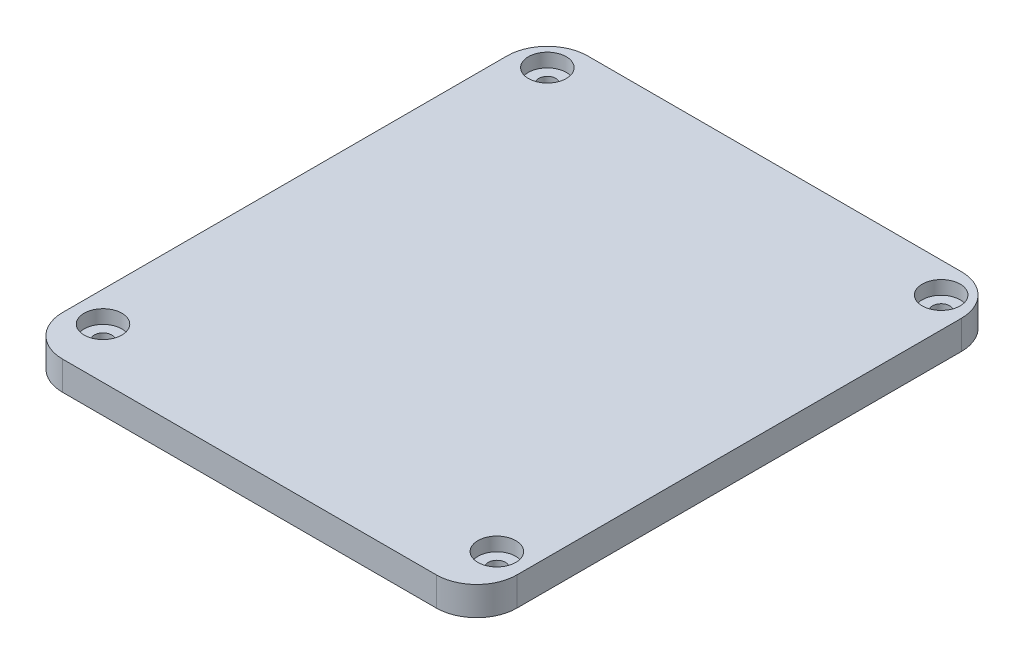
from build123d import *

# Parameters (mm, degrees)
SKETCH1_W           = 90
SKETCH1_H           = 100
BOSS_EXTRUDE1_DEPTH = 3
SKETCH2_R           = 1.7
CUT_EXTRUDE1_DEPTH  = 4
SKETCH4_W           = 80.2
SKETCH4_H           = 93.2
SKETCH4_W_2         = 74.2
SKETCH4_H_2         = 87.2
BOSS_EXTRUDE2_DEPTH = 2
CUT_EXTRUDE5_START  = -3
SKETCH6_R           = 6
CUT_EXTRUDE5_DEPTH  = 3
SKETCH7_W           = 90
SKETCH7_H           = 3
BOSS_EXTRUDE3_DEPTH = 4
SKETCH8_R           = 3.75
BOSS_EXTRUDE4_DEPTH = 2.7
FILLET1_R           = 8


with BuildPart() as part:
    # Sketch1 → Boss-Extrude1 (new body)
    with BuildSketch(Plane(origin=(0, 0, 0), x_dir=(1, 0, 0), z_dir=(0, 1, 0))):
        Rectangle(SKETCH1_W, SKETCH1_H)
    extrude(amount=BOSS_EXTRUDE1_DEPTH)

    # Sketch2 → Cut-Extrude1 (cut, through all)
    with BuildSketch(Plane(origin=(0, 3, 0), x_dir=(1, 0, 0), z_dir=(0, 1, 0))):
        with Locations((-39, 44)):
            Circle(SKETCH2_R)
        with Locations((39, 44)):
            Circle(SKETCH2_R)
        with Locations((39, -44)):
            Circle(SKETCH2_R)
        with Locations((-39, -44)):
            Circle(SKETCH2_R)
    extrude(amount=-CUT_EXTRUDE1_DEPTH, mode=Mode.SUBTRACT)

    # Sketch4 → Boss-Extrude2 (add)
    with BuildSketch(Plane.XZ):
        with Locations((1.5, 0)):
            Rectangle(SKETCH4_W, SKETCH4_H)
        with Locations((1.5, 0)):
            Rectangle(SKETCH4_W_2, SKETCH4_H_2, mode=Mode.SUBTRACT)
    extrude(amount=BOSS_EXTRUDE2_DEPTH)

    # Sketch6 → Cut-Extrude5 (cut, through all)
    with BuildSketch(Plane(origin=(0, 3, 0), x_dir=(1, 0, 0), z_dir=(0, 1, 0)).offset(CUT_EXTRUDE5_START)):
        with Locations((-39, 44)):
            Circle(SKETCH6_R)
        with Locations((-39, -44)):
            Circle(SKETCH6_R)
        with Locations((39, -44)):
            Circle(SKETCH6_R)
        with Locations((39, 44)):
            Circle(SKETCH6_R)
    extrude(amount=-CUT_EXTRUDE5_DEPTH, mode=Mode.SUBTRACT)

    # Sketch7 → Boss-Extrude3 (add)
    with BuildSketch(Plane.XY.offset(50)):
        with Locations((0, 1.5)):
            Rectangle(SKETCH7_W, SKETCH7_H)
    extrude(amount=BOSS_EXTRUDE3_DEPTH)

    # Sketch8 → Boss-Extrude4 (add)
    with BuildSketch(Plane(origin=(0, 3, 0), x_dir=(1, 0, 0), z_dir=(0, 1, 0))):
        Polygon((-45, -50), (-45, -54), (45, -54), (45, -50), (45, 50), (-45, 50), align=None)
        with Locations((-39, 44)):
            Circle(SKETCH8_R, mode=Mode.SUBTRACT)
        with Locations((39, 44)):
            Circle(SKETCH8_R, mode=Mode.SUBTRACT)
        with Locations((-39, -44)):
            Circle(SKETCH8_R, mode=Mode.SUBTRACT)
        with Locations((39, -44)):
            Circle(SKETCH8_R, mode=Mode.SUBTRACT)
    extrude(amount=BOSS_EXTRUDE4_DEPTH)

    # Fillet1
    fillet1_edges = [part.edges().sort_by_distance(p)[0] for p in [
        (-45, 2.85, 54),
        (45, 2.85, 54),
        (-45, 2.85, -50),
        (45, 2.85, -50),
    ]]
    fillet(fillet1_edges, radius=FILLET1_R)


solid = part.part
